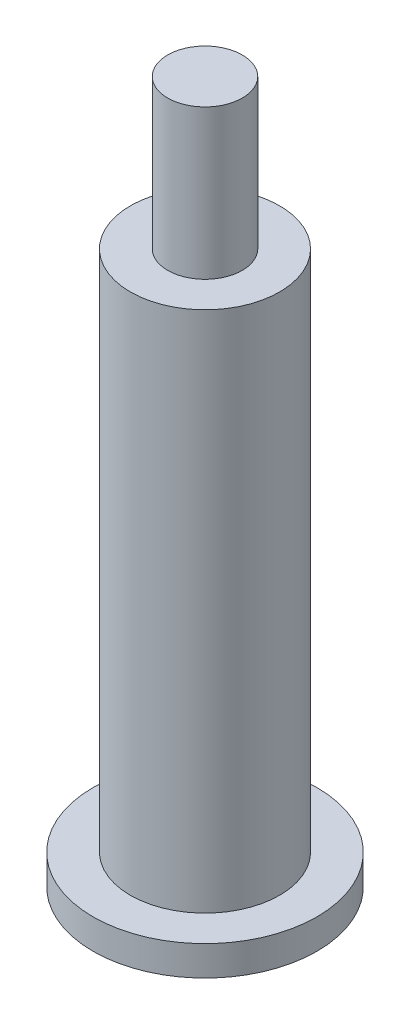
from build123d import *

# Parameters (mm, degrees)
CROQUIS1_R              = 9.525
SALIENTE_EXTRUIR1_DEPTH = 2.54
CROQUIS2_R              = 6.35
SALIENTE_EXTRUIR2_DEPTH = 44.45
CROQUIS5_R              = 3.175
SALIENTE_EXTRUIR4_DEPTH = 12.7


with BuildPart() as part:
    # Croquis1 → Saliente-Extruir1 (new body)
    with BuildSketch(Plane(origin=(0, 0, 0), x_dir=(1, 0, 0), z_dir=(0, 1, 0))):
        Circle(CROQUIS1_R)
    extrude(amount=SALIENTE_EXTRUIR1_DEPTH)

    # Croquis2 → Saliente-Extruir2 (add)
    with BuildSketch(Plane(origin=(0, 2.54, 0), x_dir=(1, 0, 0), z_dir=(0, 1, 0))):
        Circle(CROQUIS2_R)
    extrude(amount=SALIENTE_EXTRUIR2_DEPTH)

    # Croquis5 → Saliente-Extruir4 (add)
    with BuildSketch(Plane(origin=(0, 46.99, 0), x_dir=(1, 0, 0), z_dir=(0, 1, 0))):
        Circle(CROQUIS5_R)
    extrude(amount=SALIENTE_EXTRUIR4_DEPTH)


solid = part.part
